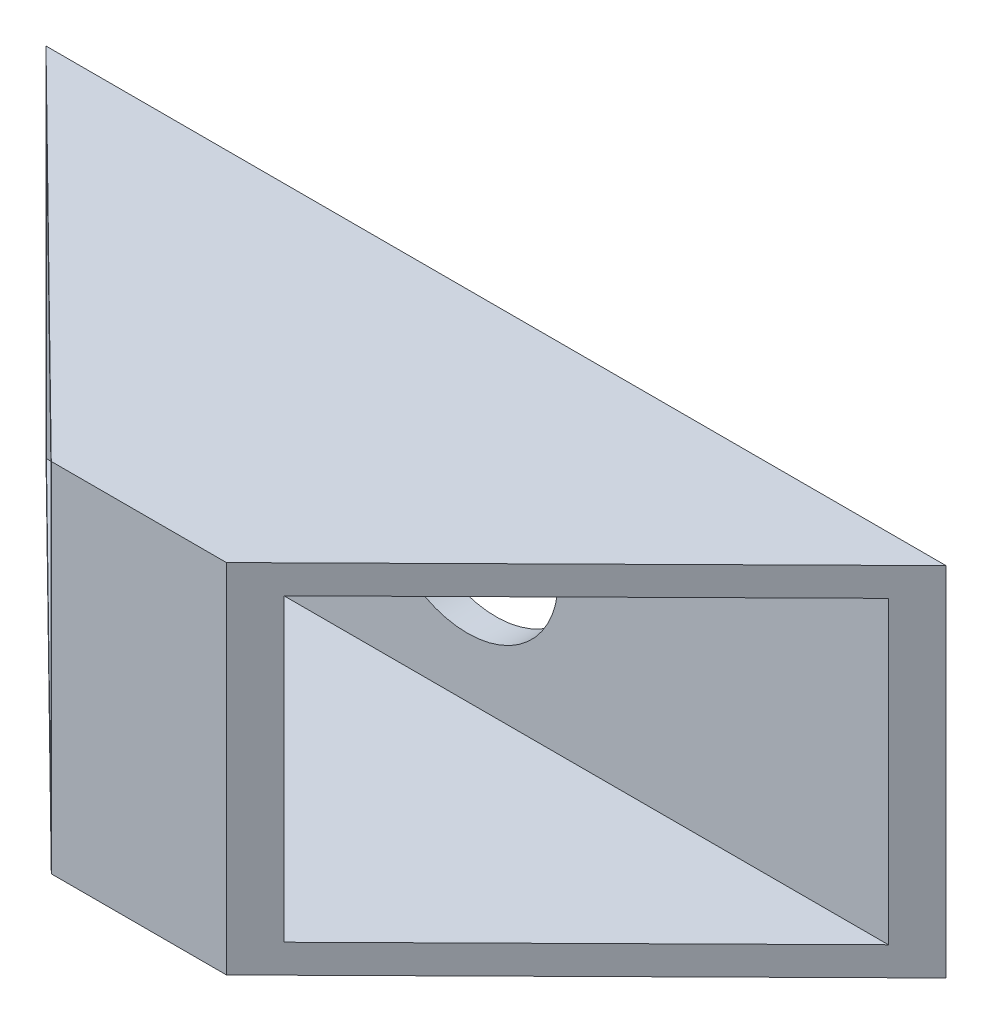
from build123d import *

# Parameters (mm, degrees)
BOSS_EXTRUDE1_DEPTH = 25
SHELL1_T            = -2
SKETCH2_R           = 6.35
CUT_EXTRUDE1_DEPTH  = 10


with BuildPart() as part:
    # Sketch1 → Boss-Extrude1 (new body)
    with BuildSketch(Plane(origin=(0, 0, 0), x_dir=(1, 0, 0), z_dir=(0, 1, 0))):
        Polygon((-17.350316623, 15.957783641), (45.649683377, 15.957783641), (20.279683377, -9.042216359), (8.019683377, -9.042216359), align=None)
    extrude(amount=BOSS_EXTRUDE1_DEPTH)

    # Shell1
    shell1_openings = [part.faces().sort_by_distance(p)[0] for p in [
        (32.964683377, 12.5, -3.457783641),
        (-4.665316623, 12.5, -3.457783641),
    ]]
    offset(amount=SHELL1_T, openings=shell1_openings, kind=Kind.INTERSECTION)

    # Sketch2 → Cut-Extrude1 (cut)
    with BuildSketch(Plane(origin=(0, 0, -15.957783641), x_dir=(-1, 0, 0), z_dir=(0, 0, -1))):
        with Locations((-14.149683377, 12.5)):
            Circle(SKETCH2_R)
    extrude(amount=-CUT_EXTRUDE1_DEPTH, mode=Mode.SUBTRACT)


solid = part.part
